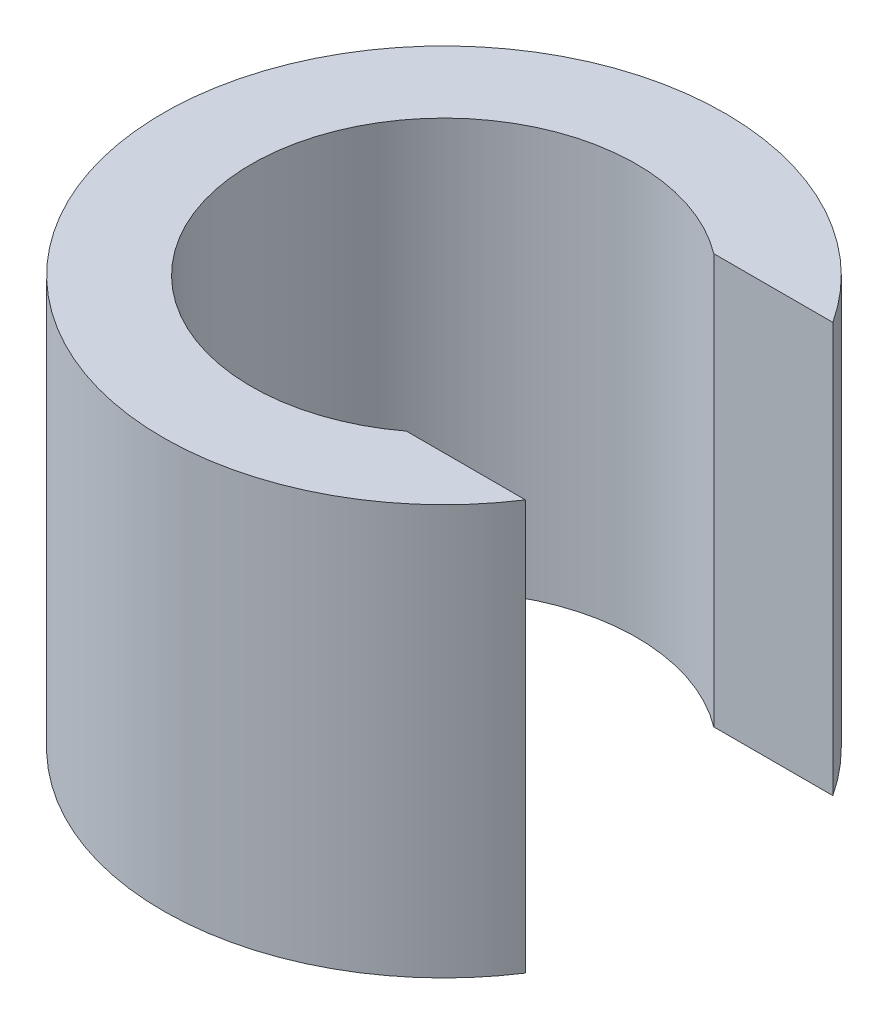
from build123d import *

# Parameters (mm, degrees)
BOSS_EXTRUDE1_DEPTH = 25.4


with BuildPart() as part:
    # Sketch1 → Boss-Extrude1 (new body)
    with BuildSketch(Plane(origin=(0, 0, 0), x_dir=(1, 0, 0), z_dir=(0, 1, 0))):
        with BuildLine():
            Line((7.196542156, 9.525), (14.575378962, 9.525))
            ThreePointArc((14.575378962, 9.525), (-17.4117, 0), (14.575378962, -9.525))
            Line((14.575378962, -9.525), (7.196542156, -9.525))
            ThreePointArc((7.196542156, -9.525), (-11.938, 0), (7.196542156, 9.525))
        make_face()
    extrude(amount=BOSS_EXTRUDE1_DEPTH)


solid = part.part
